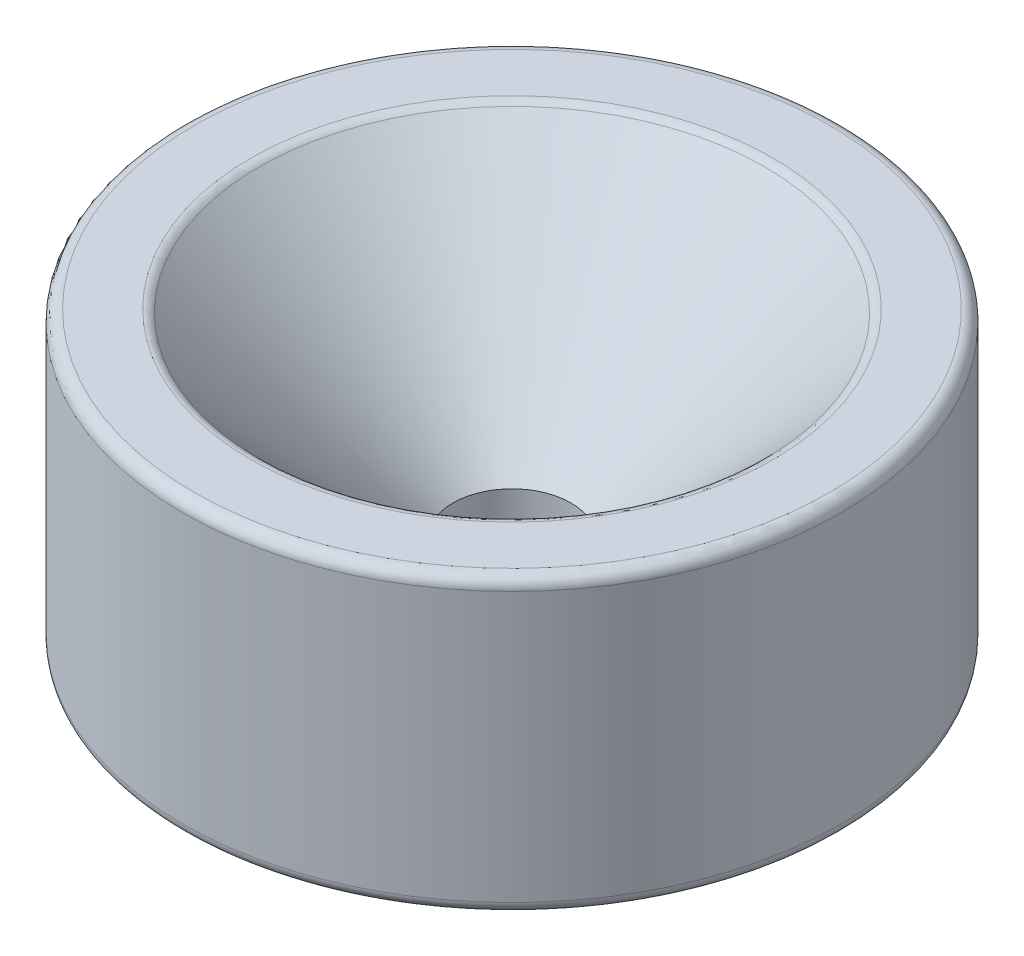
from build123d import *

# Parameters (mm, degrees)
FILLET1_R               = 0.508
F_1_4_20_TAPPED_HOLE1_D = 5.1054


with BuildPart() as part:
    # Sketch1 → Revolve1 (revolve)
    with BuildSketch(Plane.XY, mode=Mode.PRIVATE) as revolve1_sk:
        Polygon((0, 0.762), (8.763, 0.762), (9.525, 0), (14.2875, 0), (14.2875, 12.7), (11.1125, 12.7), (0, 1.5875), align=None)
    revolve(revolve1_sk.sketch.rotate(Axis((0, 0, 0), (0, 1, 0)), 90), axis=Axis((0, 0, 0), (0, 1, 0)))  # turned: the seam where the file's is

    # Fillet1
    fillet1_edges = [part.edges().sort_by_distance(p)[0] for p in [
        (0, 0, 14.2875),
        (0, 12.7, 14.2875),
        (0, 12.7, 11.1125),
    ]]
    fillet(fillet1_edges, radius=FILLET1_R)

    # 1_4-20 Tapped Hole1 (through all)
    with Locations(Plane(origin=(0, 0.762, 0), x_dir=(-1, 0, 0), z_dir=(0, -1, 0))):
        with Locations((0, 0)):
            Hole(F_1_4_20_TAPPED_HOLE1_D / 2)


solid = part.part
